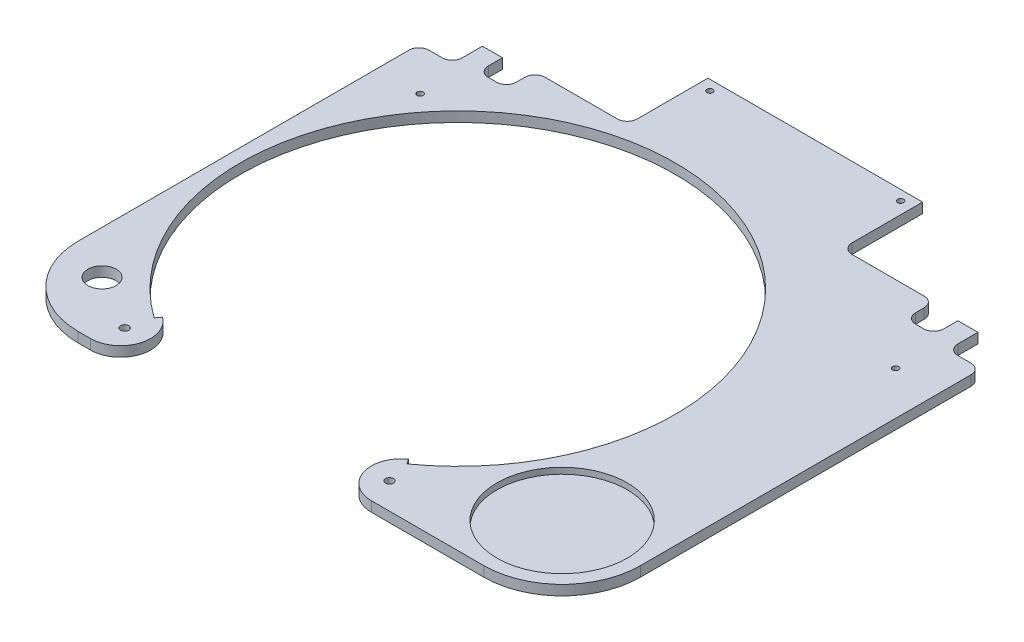
from build123d import *

# Parameters (mm, degrees)
ESQUISSE1_W              = 280.2
ESQUISSE1_H              = 276.282873123
BOSS_EXTRU_1_DEPTH       = 5
ENL_V_MAT_EXTRU_1_DEPTH  = 6
ENL_V_MAT_EXTRU_3_DEPTH  = 6
ESQUISSE5_R              = 2
ENL_V_MAT_EXTRU_4_DEPTH  = 6
ENL_V_MAT_EXTRU_5_DEPTH  = 6
ESQUISSE7_R              = 7.071067812
ENL_V_MAT_EXTRU_6_DEPTH  = 6
ESQUISSE8_R              = 1.5
ENL_V_MAT_EXTRU_8_DEPTH  = 6
ESQUISSE9_R              = 32.5
ENL_V_MAT_EXTRU_10_DEPTH = 3
ESQUISSE10_R             = 1.5
ENL_V_MAT_EXTRU_11_DEPTH = 6


with BuildPart() as part:
    # Esquisse1 → Boss.-Extru.1 (new body)
    with BuildSketch(Plane(origin=(0, 0, 0), x_dir=(1, 0, 0), z_dir=(0, 1, 0))):
        with Locations((0, -106.941436562)):
            Rectangle(ESQUISSE1_W, ESQUISSE1_H)
    extrude(amount=BOSS_EXTRU_1_DEPTH)

    # Esquisse2 → Enlèv. mat.-Extru.1 (cut, through all)
    with BuildSketch(Plane(origin=(0, 5, 0), x_dir=(1, 0, 0), z_dir=(0, 1, 0))):
        with BuildLine():
            Line((-86.286307054, -217.873386842), (-88.029045643, -220.315284098))
            ThreePointArc((-88.029045643, -220.315284098), (-128.330678708, -98.90890093), (-25, -23.5))
            ThreePointArc((-25, -23.5), (78.330678708, -98.90890093), (38.029045643, -220.315284098))
            Line((38.029045643, -220.315284098), (36.286307054, -217.873386842))
            ThreePointArc((36.286307054, -217.873386842), (30.714652713, -234.657679446), (45, -245.082873123))
            Line((45, -245.082873123), (-95, -245.082873123))
            ThreePointArc((-95, -245.082873123), (-80.714652713, -234.657679446), (-86.286307054, -217.873386842))
        make_face()
    extrude(amount=-ENL_V_MAT_EXTRU_1_DEPTH, mode=Mode.SUBTRACT)

    # Esquisse4 → Enlèv. mat.-Extru.3 (cut, through all)
    with BuildSketch(Plane(origin=(0, 5, 0), x_dir=(1, 0, 0), z_dir=(0, 1, 0))):
        with BuildLine():
            Line((140.1, -245.082873123), (101.1, -245.082873123))
            ThreePointArc((101.1, -245.082873123), (128.677164466, -233.660037589), (140.1, -206.082873123))
            Line((140.1, -206.082873123), (140.1, -245.082873123))
        make_face()
        with BuildLine():
            Line((-101.1, -245.082873123), (-140.1, -245.082873123))
            Line((-140.1, -245.082873123), (-140.1, -206.082873123))
            ThreePointArc((-140.1, -206.082873123), (-128.677164466, -233.660037589), (-101.1, -245.082873123))
        make_face()
    extrude(amount=-ENL_V_MAT_EXTRU_3_DEPTH, mode=Mode.SUBTRACT)

    # Esquisse5 → Enlèv. mat.-Extru.4 (cut, through all)
    with BuildSketch(Plane(origin=(0, 5, 0), x_dir=(1, 0, 0), z_dir=(0, 1, 0))):
        with Locations((-91, -232)):
            Circle(ESQUISSE5_R)
        with Locations((41, -232)):
            Circle(ESQUISSE5_R)
    extrude(amount=-ENL_V_MAT_EXTRU_4_DEPTH, mode=Mode.SUBTRACT)

    # Esquisse6 → Enlèv. mat.-Extru.5 (cut, through all)
    with BuildSketch(Plane(origin=(0, 5, 0), x_dir=(1, 0, 0), z_dir=(0, 1, 0))):
        with BuildLine():
            Line((140.1, 31.2), (0, 31.2))
            Line((0, 31.2), (-140.1, 31.2))
            Line((-140.1, 31.2), (-140.1, -41.25))
            ThreePointArc((-140.1, -41.25), (-138.635533906, -37.714466094), (-135.1, -36.25))
            Line((-135.1, -36.25), (-128.5, -36.25))
            ThreePointArc((-128.5, -36.25), (-124.964466094, -34.785533906), (-123.5, -31.25))
            Line((-123.5, -31.25), (-123.5, -21.2))
            Line((-123.5, -21.2), (-113.5, -21.2))
            Line((-113.5, -21.2), (-113.5, -28.25))
            ThreePointArc((-113.5, -28.25), (-112.035533906, -31.785533906), (-108.5, -33.25))
            Line((-108.5, -33.25), (-104.5, -33.25))
            ThreePointArc((-104.5, -33.25), (-100.964466094, -31.785533906), (-99.5, -28.25))
            Line((-99.5, -28.25), (-99.5, -24))
            ThreePointArc((-99.5, -24), (-98.035533906, -20.464466094), (-94.5, -19))
            Line((-94.5, -19), (-58.5, -19))
            ThreePointArc((-58.5, -19), (-54.964466094, -17.535533906), (-53.5, -14))
            Line((-53.5, -14), (-53.5, 21.2))
            Line((-53.5, 21.2), (53.5, 21.2))
            Line((53.5, 21.2), (53.5, -14))
            ThreePointArc((53.5, -14), (54.964466094, -17.535533906), (58.5, -19))
            Line((58.5, -19), (94.5, -19))
            ThreePointArc((94.5, -19), (98.035533906, -20.464466094), (99.5, -24))
            Line((99.5, -24), (99.5, -28.25))
            ThreePointArc((99.5, -28.25), (100.964466094, -31.785533906), (104.5, -33.25))
            Line((104.5, -33.25), (108.5, -33.25))
            ThreePointArc((108.5, -33.25), (112.035533906, -31.785533906), (113.5, -28.25))
            Line((113.5, -28.25), (113.5, -21.2))
            Line((113.5, -21.2), (123.5, -21.2))
            Line((123.5, -21.2), (123.5, -31.25))
            ThreePointArc((123.5, -31.25), (124.964466094, -34.785533906), (128.5, -36.25))
            Line((128.5, -36.25), (135.1, -36.25))
            ThreePointArc((135.1, -36.25), (138.635533906, -37.714466094), (140.1, -41.25))
            Line((140.1, -41.25), (140.1, 31.2))
        make_face()
    extrude(amount=-ENL_V_MAT_EXTRU_5_DEPTH, mode=Mode.SUBTRACT)

    # Esquisse7 → Enlèv. mat.-Extru.6 (cut, through all)
    with BuildSketch(Plane(origin=(0, 5, 0), x_dir=(1, 0, 0), z_dir=(0, 1, 0))):
        with Locations((-118.5, -215.8)):
            Circle(ESQUISSE7_R)
    extrude(amount=-ENL_V_MAT_EXTRU_6_DEPTH, mode=Mode.SUBTRACT)

    # Esquisse8 → Enlèv. mat.-Extru.8 (cut, through all)
    with BuildSketch(Plane.XZ):
        with Locations((47.5, -16.2)):
            Circle(ESQUISSE8_R)
        with Locations((-47.5, -16.2)):
            Circle(ESQUISSE8_R)
    extrude(amount=-ENL_V_MAT_EXTRU_8_DEPTH, mode=Mode.SUBTRACT)

    # Esquisse9 → Enlèv. mat.-Extru.10 (cut)
    with BuildSketch(Plane(origin=(0, 5, 0), x_dir=(1, 0, 0), z_dir=(0, 1, 0))):
        with Locations((101.1, -206.082873123)):
            Circle(ESQUISSE9_R)
    extrude(amount=-ENL_V_MAT_EXTRU_10_DEPTH, mode=Mode.SUBTRACT)

    # Esquisse10 → Enlèv. mat.-Extru.11 (cut, through all)
    with BuildSketch(Plane(origin=(0, 5, 0), x_dir=(1, 0, 0), z_dir=(0, 1, 0))):
        with Locations((118.5, -57.265046493)):
            Circle(ESQUISSE10_R)
        with Locations((-118.5, -57.265046493)):
            Circle(ESQUISSE10_R)
    extrude(amount=-ENL_V_MAT_EXTRU_11_DEPTH, mode=Mode.SUBTRACT)


solid = part.part
